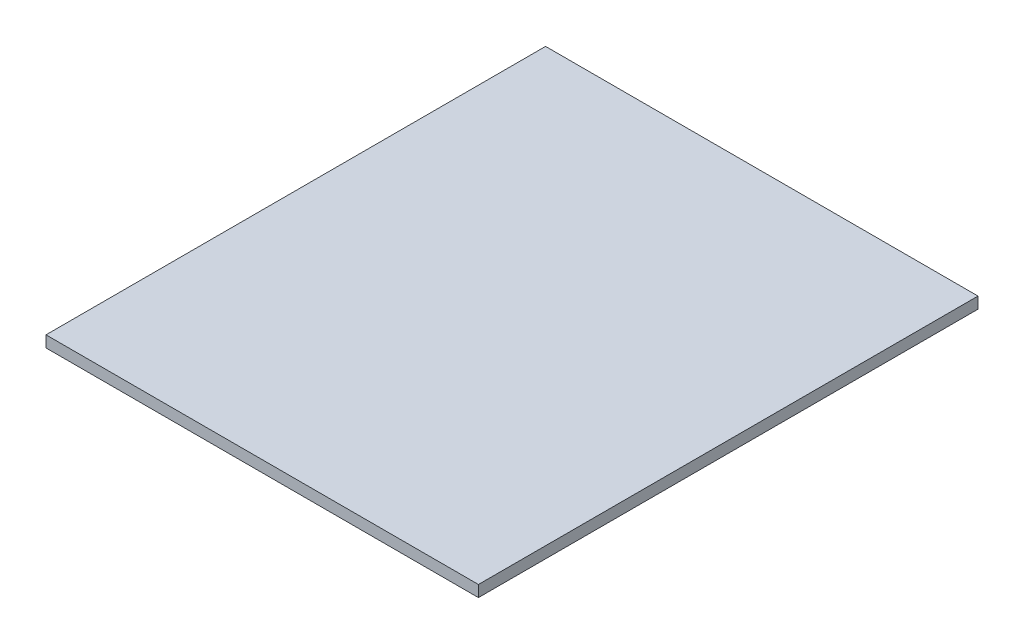
from build123d import *

# Parameters (mm, degrees)
SKETCH1_W           = 380
SKETCH1_H           = 439
BOSS_EXTRUDE1_DEPTH = 10


with BuildPart() as part:
    # Sketch1 → Boss-Extrude1 (new body)
    with BuildSketch(Plane(origin=(0, 0, 0), x_dir=(1, 0, 0), z_dir=(0, 1, 0))):
        Rectangle(SKETCH1_W, SKETCH1_H)
    extrude(amount=BOSS_EXTRUDE1_DEPTH)


solid = part.part
